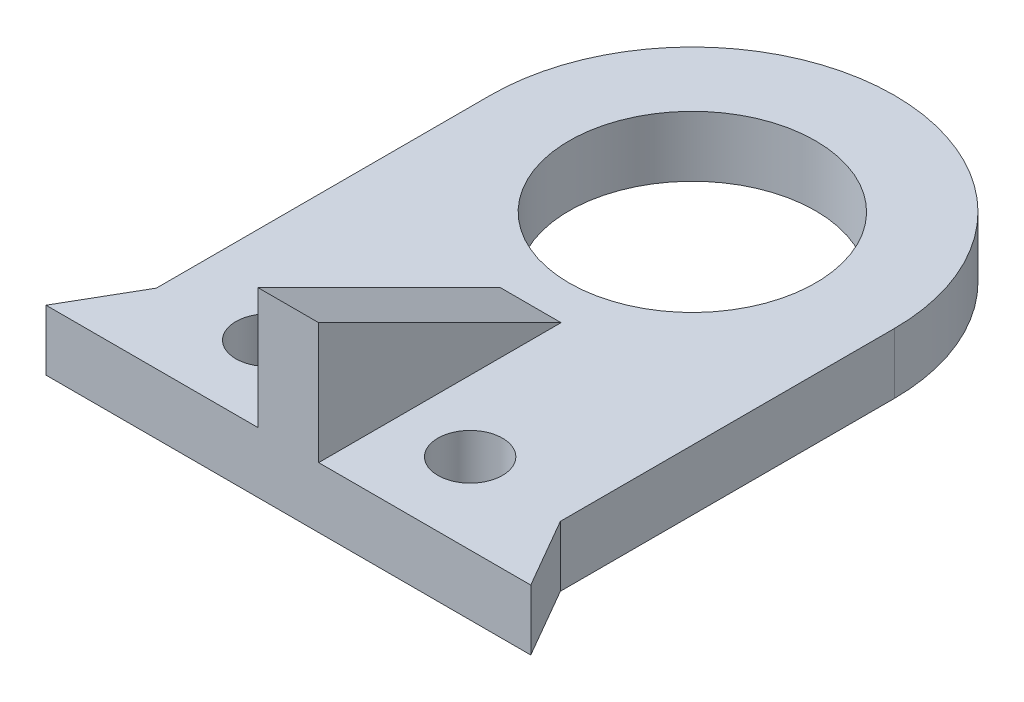
from build123d import *

# Parameters (mm, degrees)
SKETCH1_R           = 6.1
BOSS_EXTRUDE1_DEPTH = 3
SKETCH2_R           = 1.6
CUT_EXTRUDE1_DEPTH  = 4
BOSS_EXTRUDE2_DEPTH = 1.5
BOSS_EXTRUDE3_DEPTH = 3


with BuildPart() as part:
    # Sketch1 → Boss-Extrude1 (new body)
    with BuildSketch(Plane(origin=(0, 0, 0), x_dir=(1, 0, 0), z_dir=(0, 1, 0))):
        with BuildLine():
            Line((-10, -10), (10, -10))
            Line((10, -10), (10, 10))
            ThreePointArc((10, 10), (0, 20), (-10, 10))
            Line((-10, 10), (-10, -10))
        make_face()
        with Locations((0, 10)):
            Circle(SKETCH1_R, mode=Mode.SUBTRACT)
    extrude(amount=BOSS_EXTRUDE1_DEPTH)

    # Sketch2 → Cut-Extrude1 (cut, through all)
    with BuildSketch(Plane(origin=(0, 3, 0), x_dir=(1, 0, 0), z_dir=(0, 1, 0))):
        with Locations((-5, -6)):
            Circle(SKETCH2_R)
        with Locations((5, -6)):
            Circle(SKETCH2_R)
    extrude(amount=-CUT_EXTRUDE1_DEPTH, mode=Mode.SUBTRACT)

    # Sketch4 → Boss-Extrude2 (add, symmetric)
    with BuildSketch(Plane(origin=(0, 0, 0), x_dir=(0, 0, -1), z_dir=(1, 0, 0))):
        Polygon((-10, 3), (-10, 9), (2, 3), align=None)
    extrude(amount=BOSS_EXTRUDE2_DEPTH, both=True)

    # Sketch5 → Boss-Extrude3 (add)
    with BuildSketch(Plane(origin=(0, 0, 0), x_dir=(1, 0, 0), z_dir=(0, 1, 0))):
        Polygon((-10, -10), (-12, -10), (-10, -6.535898385), align=None)
        Polygon((10, -10), (12, -10), (10, -6.535898385), align=None)
    extrude(amount=BOSS_EXTRUDE3_DEPTH)


solid = part.part
